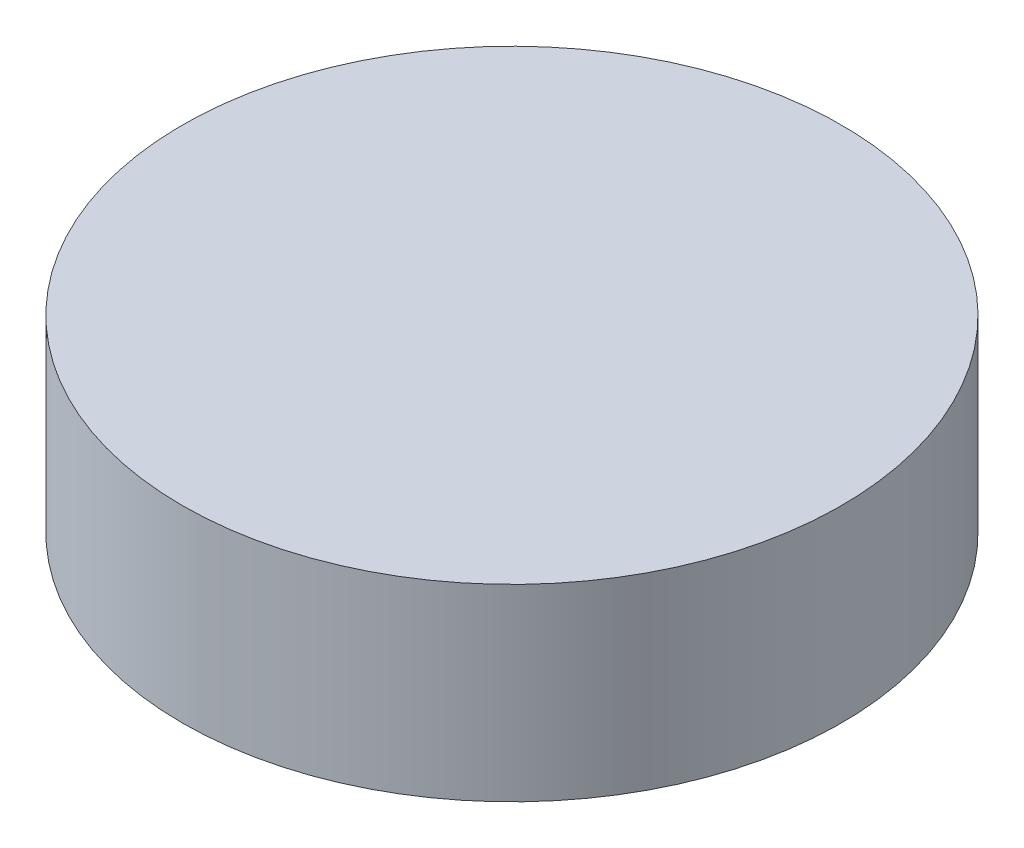
from build123d import *

# Parameters (mm, degrees)
SKETCH1_R      = 8.75
EXTRUDE1_DEPTH = 5


with BuildPart() as part:
    # Sketch1 → Extrude1 (new body)
    with BuildSketch(Plane(origin=(0, 0, 0), x_dir=(1, 0, 0), z_dir=(0, 1, 0))):
        with Locations(Location((0, 0, 0), (0, 0, 270))):  # turned: the seam where the file's is
            Circle(SKETCH1_R)
    extrude(amount=EXTRUDE1_DEPTH)


solid = part.part
